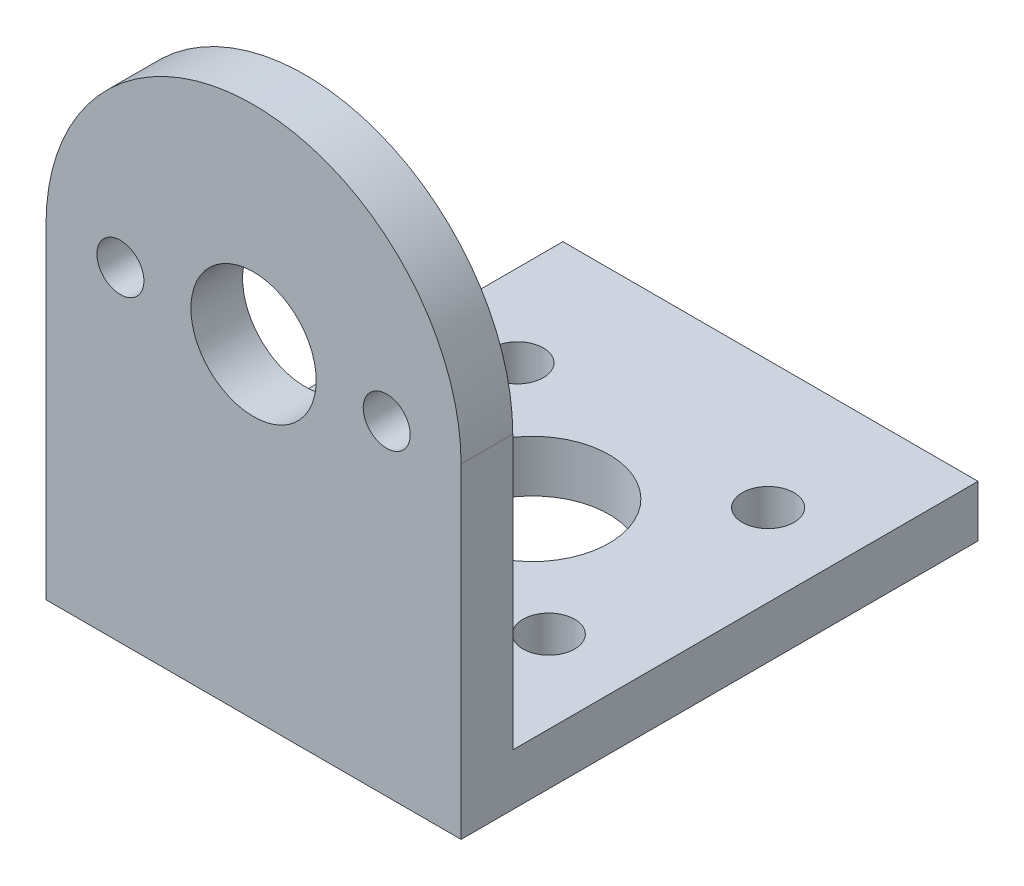
from build123d import *

# Parameters (mm, degrees)
SKETCH_1_R          = 4
SKETCH_1_R_2        = 1.5
EXTRUDE_1_DEPTH     = 3.3
SKETCH_2_W          = 26.5
SKETCH_2_H          = 3.3
EXTRUDE_2_DEPTH     = 29.7
SKETCH_3_R          = 4.9
SKETCH_3_R_2        = 1.65
CUT_EXTRUDE_1_DEPTH = 3.3


with BuildPart() as part:
    # 草图1 → 凸台-拉伸1 (new body)
    with BuildSketch(Plane.XY):
        with BuildLine():
            Line((-13.25, 0), (-13.25, -20.75))
            Line((-13.25, -20.75), (13.25, -20.75))
            Line((13.25, -20.75), (13.25, 0))
            ThreePointArc((13.25, 0), (0, 13.25), (-13.25, 0))
        make_face()
        Circle(SKETCH_1_R, mode=Mode.SUBTRACT)
        with Locations((-8.5, 0)):
            Circle(SKETCH_1_R_2, mode=Mode.SUBTRACT)
        with Locations((8.5, 0)):
            Circle(SKETCH_1_R_2, mode=Mode.SUBTRACT)
    extrude(amount=EXTRUDE_1_DEPTH)

    # 草图2 → 凸台-拉伸2 (add)
    with BuildSketch(Plane.XY):
        with Locations((0, -19.1)):
            Rectangle(SKETCH_2_W, SKETCH_2_H)
    extrude(amount=-EXTRUDE_2_DEPTH)

    # 草图3 → 切除-拉伸1 (cut)
    with BuildSketch(Plane(origin=(0, -17.45, 0), x_dir=(1, 0, 0), z_dir=(0, 1, 0))):
        with Locations((0, 14.5)):
            Circle(SKETCH_3_R)
        with Locations((-8, 21.55)):
            Circle(SKETCH_3_R_2)
        with Locations((-8, 7.55)):
            Circle(SKETCH_3_R_2)
        with Locations((8, 7.55)):
            Circle(SKETCH_3_R_2)
        with Locations((8, 21.55)):
            Circle(SKETCH_3_R_2)
    extrude(amount=-CUT_EXTRUDE_1_DEPTH, mode=Mode.SUBTRACT)


solid = part.part
